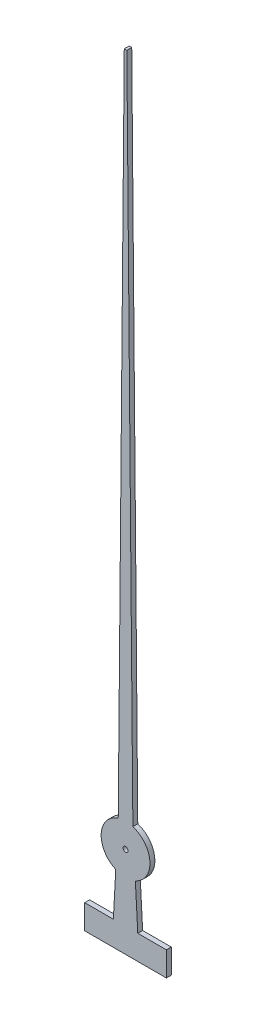
from build123d import *

# Parameters (mm, degrees)
SKETCH1_R           = 0.05
BOSS_EXTRUDE1_DEPTH = 0.1


with BuildPart() as part:
    # Sketch1 → Boss-Extrude1 (new body)
    with BuildSketch(Plane.XY):
        with BuildLine():
            Line((0.200773833, -0.457919063), (0.25, -1.364310845))
            Line((0.25, -1.364310845), (0.836414697, -1.364310845))
            Line((0.836414697, -1.364310845), (0.836414697, -1.864310845))
            Line((0.836414697, -1.864310845), (-0.836414697, -1.864310845))
            Line((-0.836414697, -1.864310845), (-0.836414697, -1.364310845))
            Line((-0.836414697, -1.364310845), (-0.25, -1.364310845))
            Line((-0.25, -1.364310845), (-0.200773833, -0.457919063))
            ThreePointArc((-0.200773833, -0.457919063), (-0.499264232, 0.027115056), (-0.15, 0.476969601))
            Line((-0.15, 0.476969601), (-0.026526263, 14.188856359))
            Line((-0.026526263, 14.188856359), (0.026526263, 14.188856359))
            Line((0.026526263, 14.188856359), (0.15, 0.476969601))
            ThreePointArc((0.15, 0.476969601), (0.499264232, 0.027115056), (0.200773833, -0.457919063))
        make_face()
        Circle(SKETCH1_R, mode=Mode.SUBTRACT)
    extrude(amount=BOSS_EXTRUDE1_DEPTH)


solid = part.part
